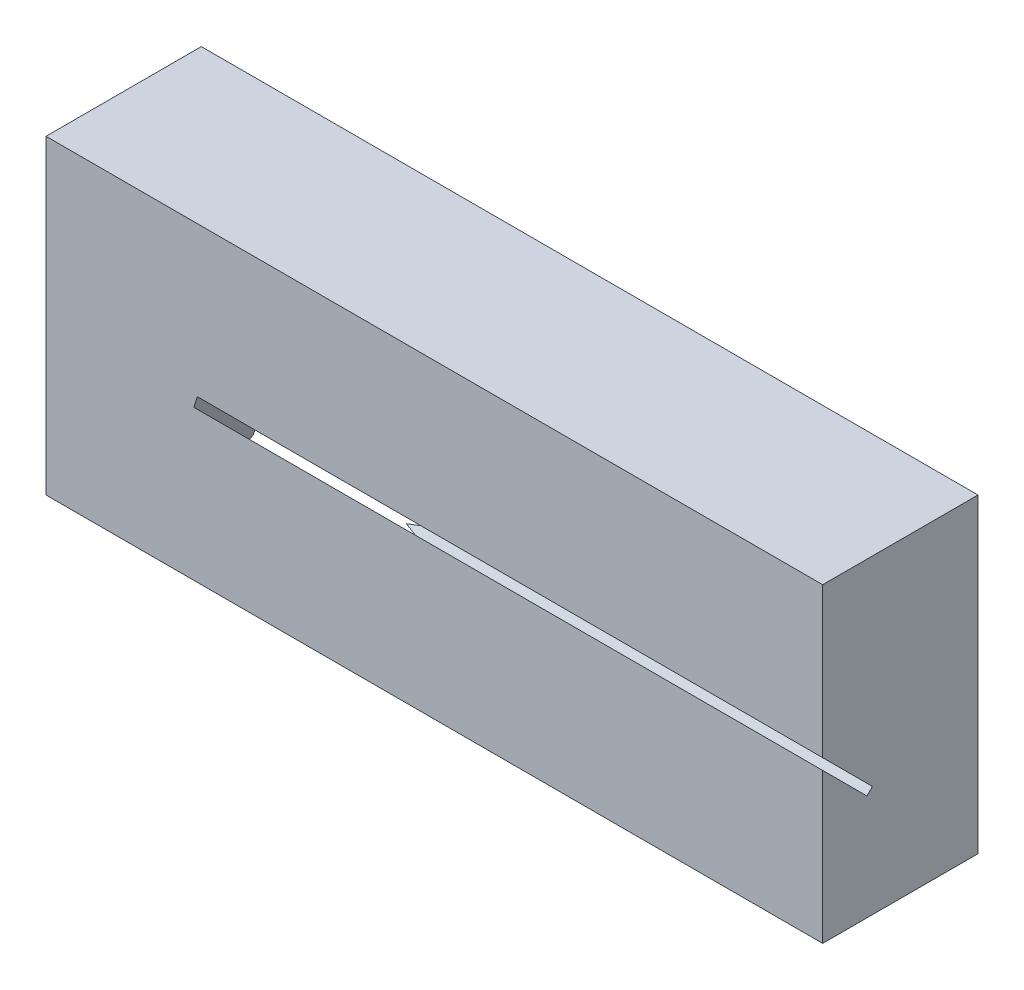
from build123d import *

# Parameters (mm, degrees)
SKETCH1_W           = 50
SKETCH1_H           = 20
BOSS_EXTRUDE1_DEPTH = 10
CUT_EXTRUDE1_DEPTH  = 0.25


with BuildPart() as part:
    # Sketch1 → Boss-Extrude1 (new body)
    with BuildSketch(Plane.XY):
        Rectangle(SKETCH1_W, SKETCH1_H)
    extrude(amount=BOSS_EXTRUDE1_DEPTH)

    # Sketch2 → Cut-Extrude1 (cut, symmetric)
    with BuildSketch(Plane(origin=(0, -5, 5), x_dir=(1, 0, 0), z_dir=(0, -0.707106781, 0.707106781))):
        Polygon((-23, -10.071067812), (35.375550351, 5.570613762), (29.163893269, 28.752833593), (-10.439065609, 18.141252744), align=None)
    extrude(amount=CUT_EXTRUDE1_DEPTH, both=True, mode=Mode.SUBTRACT)


solid = part.part
